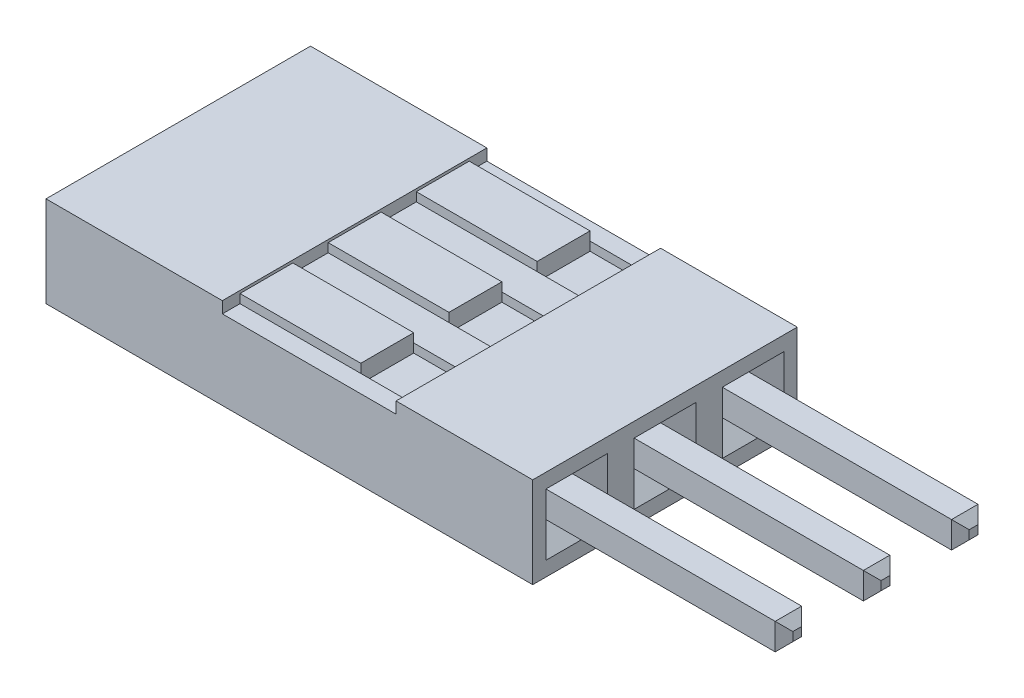
from build123d import *

# Parameters (mm, degrees)
SKETCH1_W           = 14.0208
SKETCH1_H           = 7.62
BOSS_EXTRUDE1_DEPTH = 1.3081
SKETCH2_W           = 0.762
SKETCH2_H           = 0.762
CUT_EXTRUDE1_DEPTH  = 6.35
CHAMFER1_SIZE       = 0.508
SKETCH3_W           = 1.778
SKETCH3_H           = 1.778
CUT_EXTRUDE2_DEPTH  = 0.254
SKETCH4_R           = 0.762
CUT_EXTRUDE3_DEPTH  = 5.08
SKETCH5_W           = 5.0038
SKETCH5_H           = 0.6604
CUT_EXTRUDE4_DEPTH  = 8.62
SKETCH6_W           = 1.524
SKETCH6_H           = 0.381
SKETCH6_H_2         = 0.762
SKETCH6_H_3         = 1.524
CUT_EXTRUDE5_DEPTH  = 0.254
SKETCH7_W           = 1.524
SKETCH7_H           = 0.254
BOSS_EXTRUDE2_DEPTH = 3.4798
SKETCH8_W           = 0.762
SKETCH8_H           = 0.762
BOSS_EXTRUDE3_DEPTH = 12.7
CHAMFER2_SIZE       = 0.254


with BuildPart() as part:
    # Sketch1 → Boss-Extrude1 (new body, symmetric)
    with BuildSketch(Plane(origin=(0, 0, 0), x_dir=(1, 0, 0), z_dir=(0, 1, 0))):
        Rectangle(SKETCH1_W, SKETCH1_H)
    extrude(amount=BOSS_EXTRUDE1_DEPTH, both=True)

    # Sketch2 → Cut-Extrude1 (cut)
    with BuildSketch(Plane(origin=(7.0104, 0, 0), x_dir=(0, 0, -1), z_dir=(1, 0, 0))):
        Rectangle(SKETCH2_W, SKETCH2_H)
        with Locations((-2.54, 0)):
            Rectangle(SKETCH2_W, SKETCH2_H)
        with Locations((2.54, 0)):
            Rectangle(SKETCH2_W, SKETCH2_H)
    extrude(amount=-CUT_EXTRUDE1_DEPTH, mode=Mode.SUBTRACT)

    # Chamfer1
    chamfer1_edges = [part.edges().sort_by_distance(p)[0] for p in [
        (7.0104, -0.381, 2.54),
        (7.0104, 0, 2.159),
        (7.0104, 0.381, 2.54),
        (7.0104, 0, 2.921),
        (7.0104, -0.381, 0),
        (7.0104, 0, -0.381),
        (7.0104, 0.381, 0),
        (7.0104, 0, 0.381),
        (7.0104, -0.381, -2.54),
        (7.0104, 0, -2.921),
        (7.0104, 0.381, -2.54),
        (7.0104, 0, -2.159),
    ]]
    chamfer(chamfer1_edges, length=CHAMFER1_SIZE)

    # Sketch3 → Cut-Extrude2 (cut)
    with BuildSketch(Plane.ZY.offset(7.0104)):
        with Locations((-2.54, 0)):
            Rectangle(SKETCH3_W, SKETCH3_H)
        Rectangle(SKETCH3_W, SKETCH3_H)
        with Locations((2.54, 0)):
            Rectangle(SKETCH3_W, SKETCH3_H)
    extrude(amount=-CUT_EXTRUDE2_DEPTH, mode=Mode.SUBTRACT)

    # Sketch4 → Cut-Extrude3 (cut)
    with BuildSketch(Plane.ZY.offset(6.7564)):
        with Locations((-2.54, 0)):
            Circle(SKETCH4_R)
        Circle(SKETCH4_R)
        with Locations((2.54, 0)):
            Circle(SKETCH4_R)
    extrude(amount=-CUT_EXTRUDE3_DEPTH, mode=Mode.SUBTRACT)

    # Sketch5 → Cut-Extrude4 (cut, through all)
    with BuildSketch(Plane.XY.offset(3.81)):
        with Locations((0.5715, 1.3081)):
            Rectangle(SKETCH5_W, SKETCH5_H)
    extrude(amount=-CUT_EXTRUDE4_DEPTH, mode=Mode.SUBTRACT)

    # Sketch6 → Cut-Extrude5 (cut)
    with BuildSketch(Plane(origin=(0, 0.9779, 0), x_dir=(1, 0, 0), z_dir=(0, 1, 0))):
        with Locations((2.3114, 3.1115)):
            Rectangle(SKETCH6_W, SKETCH6_H)
        with Locations((2.3114, 2.54)):
            Rectangle(SKETCH6_W, SKETCH6_H_2)
        with Locations((2.3114, 1.9685)):
            Rectangle(SKETCH6_W, SKETCH6_H)
        with Locations((2.3114, 0)):
            Rectangle(SKETCH6_W, SKETCH6_H_3)
        with Locations((2.3114, -2.54)):
            Rectangle(SKETCH6_W, SKETCH6_H_3)
    extrude(amount=-CUT_EXTRUDE5_DEPTH, mode=Mode.SUBTRACT)

    # Sketch7 → Boss-Extrude2 (add)
    with BuildSketch(Plane(origin=(-1.9304, 0, 0), x_dir=(0, 0, -1), z_dir=(1, 0, 0))):
        with Locations((2.54, 1.1049)):
            Rectangle(SKETCH7_W, SKETCH7_H)
        with Locations((0, 1.1049)):
            Rectangle(SKETCH7_W, SKETCH7_H)
        with Locations((-2.54, 1.1049)):
            Rectangle(SKETCH7_W, SKETCH7_H)
    extrude(amount=BOSS_EXTRUDE2_DEPTH)

    # Sketch8 → Boss-Extrude3 (add)
    with BuildSketch(Plane(origin=(0.6604, 0, 0), x_dir=(0, 0, -1), z_dir=(1, 0, 0))):
        with Locations((-2.54, 0)):
            Rectangle(SKETCH8_W, SKETCH8_H)
        Rectangle(SKETCH8_W, SKETCH8_H)
        with Locations((2.54, 0)):
            Rectangle(SKETCH8_W, SKETCH8_H)
    extrude(amount=BOSS_EXTRUDE3_DEPTH)

    # Chamfer2
    chamfer2_edges = [part.edges().sort_by_distance(p)[0] for p in [
        (13.3604, 0, 2.921),
        (13.3604, -0.381, 2.54),
        (13.3604, 0, 2.159),
        (13.3604, 0.381, 2.54),
        (13.3604, 0, 0.381),
        (13.3604, -0.381, 0),
        (13.3604, 0, -0.381),
        (13.3604, 0.381, 0),
        (13.3604, 0, -2.159),
        (13.3604, -0.381, -2.54),
        (13.3604, 0, -2.921),
        (13.3604, 0.381, -2.54),
    ]]
    chamfer(chamfer2_edges, length=CHAMFER2_SIZE)


solid = part.part
